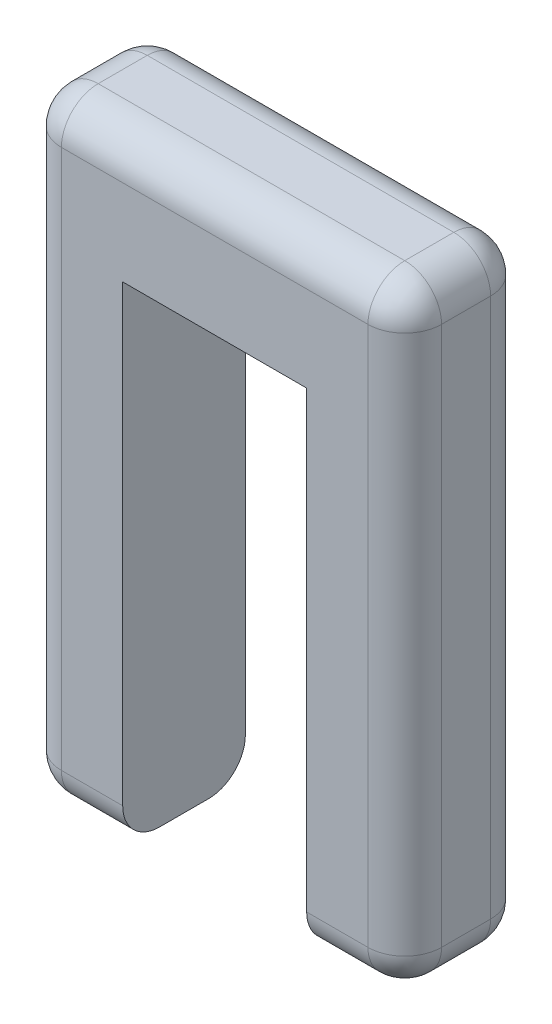
from build123d import *

# Parameters (mm, degrees)
BOSS_EXTRUDE1_DEPTH = 50
FILLET1_R           = 15


with BuildPart() as part:
    # Sketch1 → Boss-Extrude1 (new body)
    with BuildSketch(Plane.XY):
        Polygon((-37.5, -200), (-37.5, 0), (37.5, 0), (37.5, -200), (77.5, -200), (77.5, 50), (-77.5, 50), (-77.5, -200), align=None)
    extrude(amount=BOSS_EXTRUDE1_DEPTH)

    # Fillet1
    fillet1_edges = [part.edges().sort_by_distance(p)[0] for p in [
        (-57.5, -200, 0),
        (-77.5, -200, 25),
        (-77.5, 50, 25),
        (77.5, 50, 25),
        (77.5, -200, 25),
        (57.5, -200, 50),
        (77.5, -75, 50),
        (0, 50, 50),
        (-77.5, -75, 50),
        (-57.5, -200, 50),
        (-77.5, -75, 0),
        (0, 50, 0),
        (77.5, -75, 0),
        (57.5, -200, 0),
    ]]
    fillet(fillet1_edges, radius=FILLET1_R)


solid = part.part
